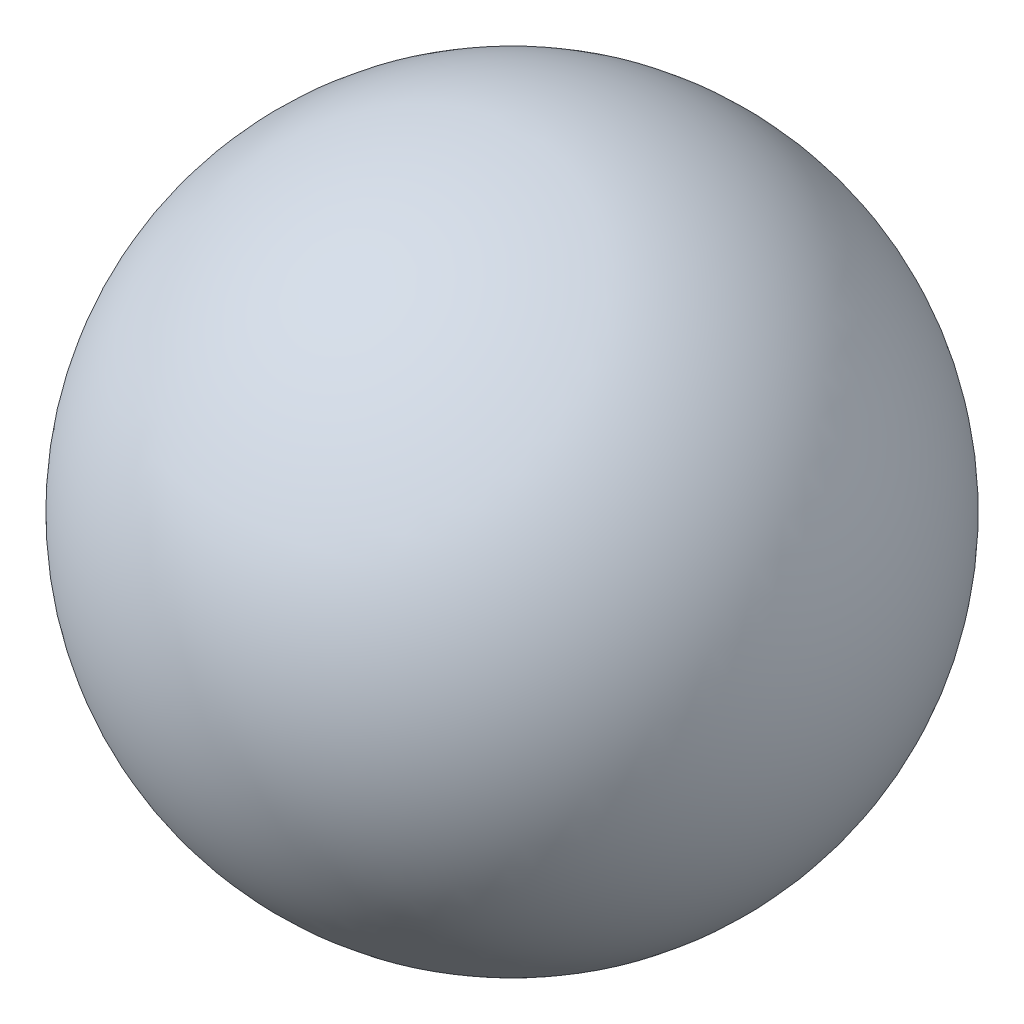
from build123d import *


with BuildPart() as part:
    # Schizzo1 → Rivoluzione1 (revolve)
    with BuildSketch(Plane(origin=(0, 0, 0), x_dir=(0, 0, -1), z_dir=(1, 0, 0))):
        with BuildLine():
            Line((0, -22), (0, 22))
            ThreePointArc((0, 22), (22, 0), (0, -22))
        make_face()
    revolve(axis=Axis((0, -22, 0), (0, 1, 0)))


solid = part.part
